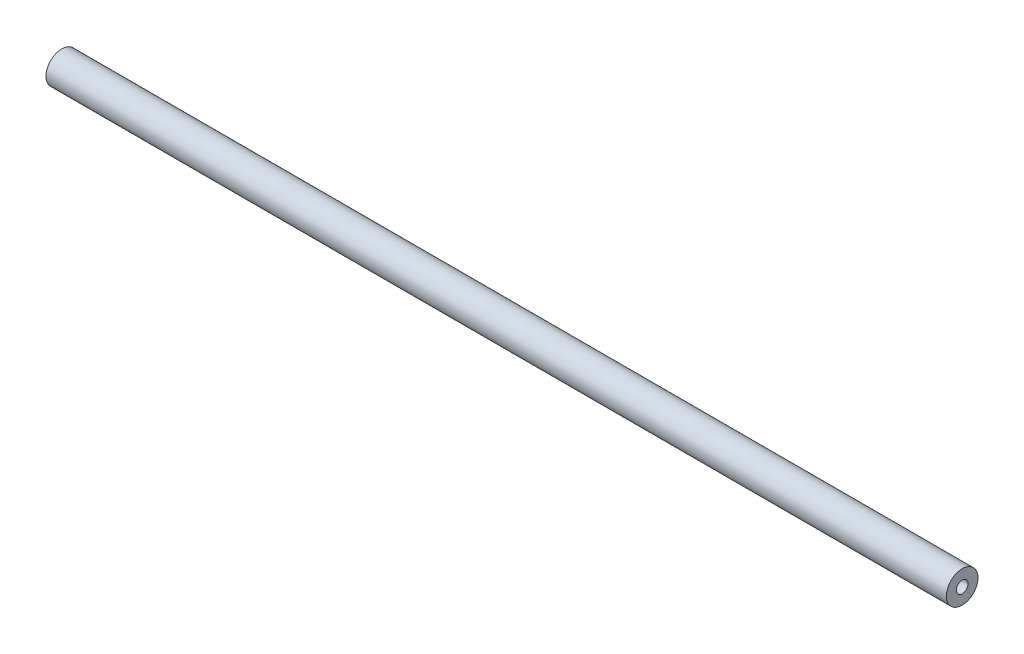
from build123d import *

# Parameters (mm, degrees)
SKETCH1_R           = 12.7
SKETCH1_R_2         = 4.7625
BOSS_EXTRUDE1_DEPTH = 723.9


with BuildPart() as part:
    # Sketch1 → Boss-Extrude1 (new body)
    with BuildSketch(Plane(origin=(0, 0, 0), x_dir=(0, 0, -1), z_dir=(1, 0, 0))):
        Circle(SKETCH1_R)
        Circle(SKETCH1_R_2, mode=Mode.SUBTRACT)
    extrude(amount=BOSS_EXTRUDE1_DEPTH)


solid = part.part
